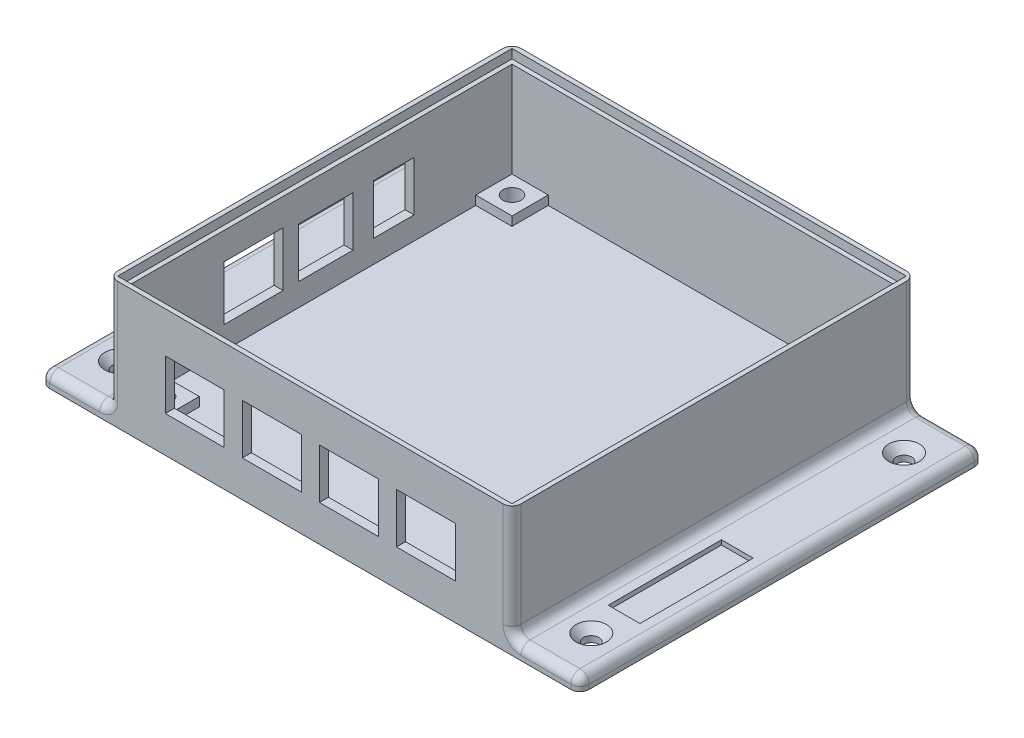
from build123d import *

# Parameters (mm, degrees)
SKETCH1_W                    = 119
SKETCH1_H                    = 89
BOSS_EXTRUDE2_DEPTH          = 3
SKETCH3_W                    = 89
SKETCH3_H                    = 89
SKETCH3_W_2                  = 85
SKETCH3_H_2                  = 85
BOSS_EXTRUDE3_DEPTH          = 25
SKETCH4_W                    = 87
SKETCH4_H                    = 87
CUT_EXTRUDE1_DEPTH           = 2
SKETCH6_W                    = 8
SKETCH6_H                    = 8
BOSS_EXTRUDE4_DEPTH          = 2
SKETCH7_R                    = 2
CUT_EXTRUDE2_DEPTH           = 4.8
SKETCH8_W                    = 9
SKETCH8_H                    = 11
SKETCH8_W_2                  = 12
SKETCH8_W_3                  = 13
SKETCH8_H_2                  = 12
CUT_EXTRUDE3_DEPTH           = 2
SKETCH9_W                    = 13
SKETCH9_H                    = 11
CUT_EXTRUDE4_DEPTH           = 2
SKETCH10_R                   = 1.6
CUT_EXTRUDE5_DEPTH           = 3
SKETCH11_W                   = 7
SKETCH11_H                   = 25
CUT_EXTRUDE6_DEPTH           = 1
FILLET2_R                    = 2
CSK_FOR_M3_SFHCS1_AT_2_COUNT = 2
CSK_FOR_M3_SFHCS1_AT_2_PITCH = 69
CSK_FOR_M3_SFHCS1_AT_3_COUNT = 2
CSK_FOR_M3_SFHCS1_AT_3_PITCH = 124.807852317
CSK_FOR_M3_SFHCS1_AT_4_COUNT = 2
CSK_FOR_M3_SFHCS1_AT_4_PITCH = 104


with BuildPart() as part:
    # Sketch1 → Boss-Extrude2 (new body)
    with BuildSketch(Plane(origin=(0, 0, 0), x_dir=(1, 0, 0), z_dir=(0, 1, 0))):
        Rectangle(SKETCH1_W, SKETCH1_H)
    extrude(amount=BOSS_EXTRUDE2_DEPTH)

    # Sketch3 → Boss-Extrude3 (add)
    with BuildSketch(Plane(origin=(0, 3, 0), x_dir=(1, 0, 0), z_dir=(0, 1, 0))):
        Rectangle(SKETCH3_W, SKETCH3_H)
        Rectangle(SKETCH3_W_2, SKETCH3_H_2, mode=Mode.SUBTRACT)
    extrude(amount=BOSS_EXTRUDE3_DEPTH)

    # Sketch4 → Cut-Extrude1 (cut)
    with BuildSketch(Plane(origin=(0, 28, 0), x_dir=(1, 0, 0), z_dir=(0, 1, 0))):
        Rectangle(SKETCH4_W, SKETCH4_H)
    extrude(amount=-CUT_EXTRUDE1_DEPTH, mode=Mode.SUBTRACT)

    # Sketch6 → Boss-Extrude4 (add)
    with BuildSketch(Plane(origin=(0, 3, 0), x_dir=(1, 0, 0), z_dir=(0, 1, 0))):
        with Locations((-38.5, -38.5)):
            Rectangle(SKETCH6_W, SKETCH6_H)
        with Locations((-38.5, 38.5)):
            Rectangle(SKETCH6_W, SKETCH6_H)
        with Locations((38.5, 38.5)):
            Rectangle(SKETCH6_W, SKETCH6_H)
        with Locations((38.5, -38.5)):
            Rectangle(SKETCH6_W, SKETCH6_H)
    extrude(amount=BOSS_EXTRUDE4_DEPTH)

    # Sketch7 → Cut-Extrude2 (cut)
    with BuildSketch(Plane(origin=(0, 5, 0), x_dir=(1, 0, 0), z_dir=(0, 1, 0))):
        with Locations((-38.5, 38.5)):
            Circle(SKETCH7_R)
        with Locations((38.5, 38.5)):
            Circle(SKETCH7_R)
        with Locations((-38.5, -38.5)):
            Circle(SKETCH7_R)
        with Locations((38.5, -38.5)):
            Circle(SKETCH7_R)
    extrude(amount=-CUT_EXTRUDE2_DEPTH, mode=Mode.SUBTRACT)

    # Sketch8 → Cut-Extrude3 (cut)
    with BuildSketch(Plane(origin=(-42.5, 0, 0), x_dir=(0, 0, -1), z_dir=(1, 0, 0))):
        with Locations((16.4, 13.5)):
            Rectangle(SKETCH8_W, SKETCH8_H)
        with Locations((1.4, 13.5)):
            Rectangle(SKETCH8_W_2, SKETCH8_H)
        with Locations((-14.5, 14)):
            Rectangle(SKETCH8_W_3, SKETCH8_H_2)
    extrude(amount=-CUT_EXTRUDE3_DEPTH, mode=Mode.SUBTRACT)

    # Sketch9 → Cut-Extrude4 (cut)
    with BuildSketch(Plane(origin=(0, 0, 42.5), x_dir=(-1, 0, 0), z_dir=(0, 0, -1))):
        with Locations((8.5, 13.5)):
            Rectangle(SKETCH9_W, SKETCH9_H)
        with Locations((25.5, 13.5)):
            Rectangle(SKETCH9_W, SKETCH9_H)
        with Locations((-8.5, 13.5)):
            Rectangle(SKETCH9_W, SKETCH9_H)
        with Locations((-25.5, 13.5)):
            Rectangle(SKETCH9_W, SKETCH9_H)
    extrude(amount=-CUT_EXTRUDE4_DEPTH, mode=Mode.SUBTRACT)

    # Sketch10 → Cut-Extrude5 (cut)
    with BuildSketch(Plane(origin=(0, 3, 0), x_dir=(1, 0, 0), z_dir=(0, 1, 0))):
        with Locations((-52, 34.5)):
            Circle(SKETCH10_R)
        with Locations((-52, -34.5)):
            Circle(SKETCH10_R)
        with Locations((52, 34.5)):
            Circle(SKETCH10_R)
        with Locations((52, -34.5)):
            Circle(SKETCH10_R)
    extrude(amount=-CUT_EXTRUDE5_DEPTH, mode=Mode.SUBTRACT)

    # Sketch11 → Cut-Extrude6 (cut)
    with BuildSketch(Plane(origin=(0, 3, 0), x_dir=(1, 0, 0), z_dir=(0, 1, 0))):
        with Locations((52, -14.77145541)):
            Rectangle(SKETCH11_W, SKETCH11_H)
    extrude(amount=-CUT_EXTRUDE6_DEPTH, mode=Mode.SUBTRACT)

    # Fillet2
    fillet2_edges = [part.edges().sort_by_distance(p)[0] for p in [
        (59.5, 3, 0),
        (52, 3, 44.5),
        (-52, 3, -44.5),
        (52, 3, -44.5),
        (-44.5, 3, 0),
        (-44.5, 15.5, -44.5),
        (-44.5, 15.5, 44.5),
        (44.5, 3, 0),
        (44.5, 15.5, 44.5),
        (44.5, 15.5, -44.5),
        (-59.5, 3, 0),
        (-59.5, 1.5, -44.5),
        (59.5, 1.5, -44.5),
        (59.5, 1.5, 44.5),
        (-59.5, 1.5, 44.5),
        (-52, 3, 44.5),
    ]]
    fillet(fillet2_edges, radius=FILLET2_R)

    # Sketch13 → CSK for M3 SFHCS1 (revolve, cut)
    with BuildSketch(Plane(origin=(52, 3, -34.5), x_dir=(0, 0, 1), z_dir=(1, 0, 0))):
        Polygon((0, 0), (0, 3), (1.7, 3), (1.7, 1.66), (3.36, 0), align=None)
    csk_for_m3_sfhcs1 = revolve(axis=Axis((52, 9.35, -34.5), (0, -1, 0)), mode=Mode.SUBTRACT)

    # CSK for M3 SFHCS1 at 2: CSK for M3 SFHCS1 ×2
    with Locations(*[(0, 0, i * CSK_FOR_M3_SFHCS1_AT_2_PITCH) for i in range(1, CSK_FOR_M3_SFHCS1_AT_2_COUNT)]):
        add(csk_for_m3_sfhcs1, mode=Mode.SUBTRACT)

    # CSK for M3 SFHCS1 at 3: CSK for M3 SFHCS1 ×2
    with Locations(*[Vector(-0.833280904, 0, 0.552849831) * (i * CSK_FOR_M3_SFHCS1_AT_3_PITCH) for i in range(1, CSK_FOR_M3_SFHCS1_AT_3_COUNT)]):
        add(csk_for_m3_sfhcs1, mode=Mode.SUBTRACT)

    # CSK for M3 SFHCS1 at 4: CSK for M3 SFHCS1 ×2
    with Locations(*[(-i * CSK_FOR_M3_SFHCS1_AT_4_PITCH, 0, 0) for i in range(1, CSK_FOR_M3_SFHCS1_AT_4_COUNT)]):
        add(csk_for_m3_sfhcs1, mode=Mode.SUBTRACT)


solid = part.part
